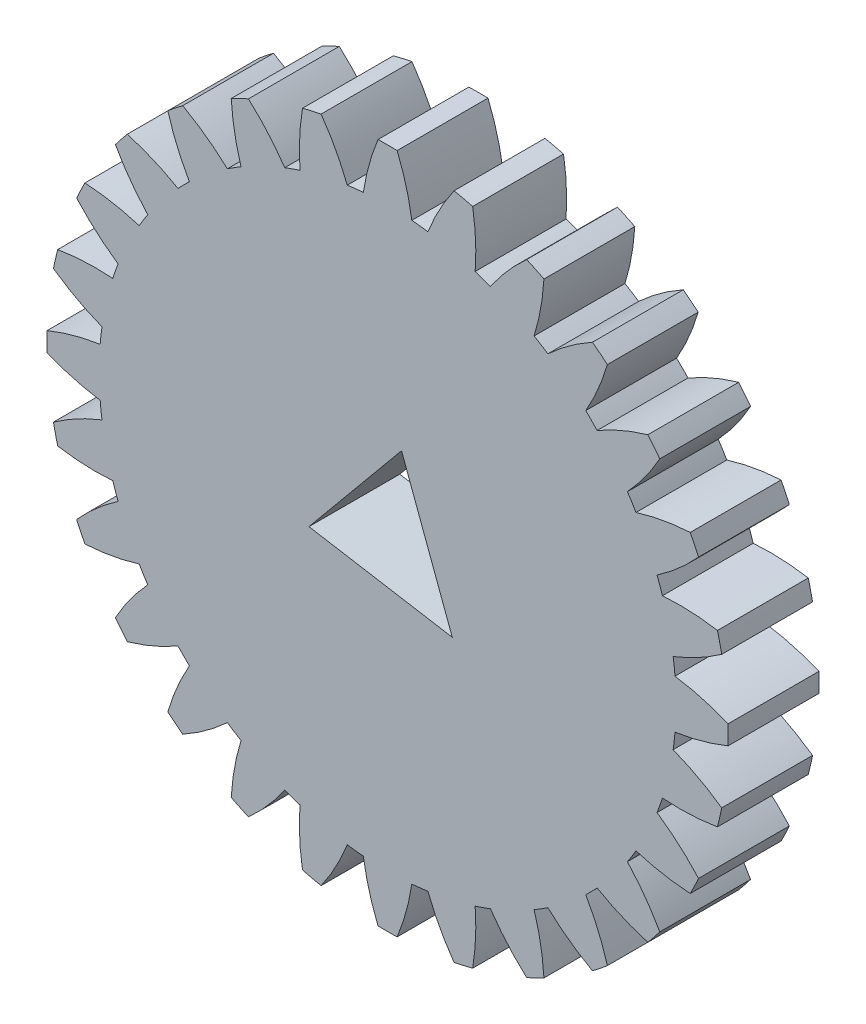
from build123d import *

# Parameters (mm, degrees)
BOSS_EXTRUDE1_DEPTH = 5


with BuildPart() as part:
    # Sketch1 → Boss-Extrude1 (new body)
    with BuildSketch(Plane.XY.offset(5)):
        with BuildLine():
            ThreePointArc((-4.820868329, 15.125305073), (-5.243180109, 14.984147869), (-5.661366831, 14.831201927))
            ThreePointArc((-5.661366831, 14.831201927), (-6.59033498, 16.033735197), (-7.658329818, 17.11468622))
            ThreePointArc((-7.658329818, 17.11468622), (-8.135320108, 16.893166273), (-8.605909959, 16.658355675))
            ThreePointArc((-8.605909959, 16.658355675), (-8.426672308, 15.149401748), (-8.065696106, 13.673337973))
            ThreePointArc((-8.065696106, 13.673337973), (-8.446009215, 13.441746663), (-8.819677449, 13.199580095))
            ThreePointArc((-8.819677449, 13.199580095), (-9.992943253, 14.165248486), (-11.274695462, 14.9814466))
            ThreePointArc((-11.274695462, 14.9814466), (-11.690433785, 14.659340296), (-12.096974691, 14.325700797))
            ThreePointArc((-12.096974691, 14.325700797), (-11.586457066, 12.894463625), (-10.906076201, 11.535732612))
            ThreePointArc((-10.906076201, 11.535732612), (-11.225320151, 11.225320151), (-11.535732612, 10.906076201))
            ThreePointArc((-11.535732612, 10.906076201), (-12.894463625, 11.586457066), (-14.325700797, 12.096974691))
            ThreePointArc((-14.325700797, 12.096974691), (-14.659340296, 11.690433785), (-14.9814466, 11.274695462))
            ThreePointArc((-14.9814466, 11.274695462), (-14.165248486, 9.992943253), (-13.199580095, 8.819677449))
            ThreePointArc((-13.199580095, 8.819677449), (-13.441746663, 8.446009215), (-13.673337973, 8.065696106))
            ThreePointArc((-13.673337973, 8.065696106), (-15.149401748, 8.426672308), (-16.658355675, 8.605909959))
            ThreePointArc((-16.658355675, 8.605909959), (-16.893166273, 8.135320108), (-17.11468622, 7.658329818))
            ThreePointArc((-17.11468622, 7.658329818), (-16.033735197, 6.59033498), (-14.831201927, 5.661366831))
            ThreePointArc((-14.831201927, 5.661366831), (-14.984147869, 5.243180109), (-15.125305073, 4.820868329))
            ThreePointArc((-15.125305073, 4.820868329), (-16.644685609, 4.844339014), (-18.15569104, 4.683308966))
            ThreePointArc((-18.15569104, 4.683308966), (-18.279898353, 4.172267512), (-18.389724008, 3.657943538))
            ThreePointArc((-18.389724008, 3.657943538), (-17.098223475, 2.857259791), (-15.719125365, 2.21917164))
            ThreePointArc((-15.719125365, 2.21917164), (-15.775181332, 1.777436058), (-15.818826219, 1.334302083))
            ThreePointArc((-15.818826219, 1.334302083), (-17.305335432, 1.019090334), (-18.742624245, 0.525867305))
            ThreePointArc((-18.742624245, 0.525867305), (-18.75, 0), (-18.742624245, -0.525867305))
            ThreePointArc((-18.742624245, -0.525867305), (-17.305335432, -1.019090334), (-15.818826219, -1.334302083))
            ThreePointArc((-15.818826219, -1.334302083), (-15.775181332, -1.777436058), (-15.719125365, -2.21917164))
            ThreePointArc((-15.719125365, -2.21917164), (-17.098223475, -2.857259791), (-18.389724008, -3.657943538))
            ThreePointArc((-18.389724008, -3.657943538), (-18.279898353, -4.172267512), (-18.15569104, -4.683308966))
            ThreePointArc((-18.15569104, -4.683308966), (-16.644685609, -4.844339014), (-15.125305073, -4.820868329))
            ThreePointArc((-15.125305073, -4.820868329), (-14.984147869, -5.243180109), (-14.831201927, -5.661366831))
            ThreePointArc((-14.831201927, -5.661366831), (-16.033735197, -6.59033498), (-17.11468622, -7.658329818))
            ThreePointArc((-17.11468622, -7.658329818), (-16.893166273, -8.135320108), (-16.658355675, -8.605909959))
            ThreePointArc((-16.658355675, -8.605909959), (-15.149401748, -8.426672308), (-13.673337973, -8.065696106))
            ThreePointArc((-13.673337973, -8.065696106), (-13.441746663, -8.446009215), (-13.199580095, -8.819677449))
            ThreePointArc((-13.199580095, -8.819677449), (-14.165248486, -9.992943253), (-14.9814466, -11.274695462))
            ThreePointArc((-14.9814466, -11.274695462), (-14.659340296, -11.690433785), (-14.325700797, -12.096974691))
            ThreePointArc((-14.325700797, -12.096974691), (-12.894463625, -11.586457066), (-11.535732612, -10.906076201))
            ThreePointArc((-11.535732612, -10.906076201), (-11.225320151, -11.225320151), (-10.906076201, -11.535732612))
            ThreePointArc((-10.906076201, -11.535732612), (-11.586457066, -12.894463625), (-12.096974691, -14.325700797))
            ThreePointArc((-12.096974691, -14.325700797), (-11.690433785, -14.659340296), (-11.274695462, -14.9814466))
            ThreePointArc((-11.274695462, -14.9814466), (-9.992943253, -14.165248486), (-8.819677449, -13.199580095))
            ThreePointArc((-8.819677449, -13.199580095), (-8.446009215, -13.441746663), (-8.065696106, -13.673337973))
            ThreePointArc((-8.065696106, -13.673337973), (-8.426672308, -15.149401748), (-8.605909959, -16.658355675))
            ThreePointArc((-8.605909959, -16.658355675), (-8.135320108, -16.893166273), (-7.658329818, -17.11468622))
            ThreePointArc((-7.658329818, -17.11468622), (-6.59033498, -16.033735197), (-5.661366831, -14.831201927))
            ThreePointArc((-5.661366831, -14.831201927), (-5.243180109, -14.984147869), (-4.820868329, -15.125305073))
            ThreePointArc((-4.820868329, -15.125305073), (-4.844339014, -16.644685609), (-4.683308966, -18.15569104))
            ThreePointArc((-4.683308966, -18.15569104), (-4.172267512, -18.279898353), (-3.657943538, -18.389724008))
            ThreePointArc((-3.657943538, -18.389724008), (-2.857259791, -17.098223475), (-2.21917164, -15.719125365))
            ThreePointArc((-2.21917164, -15.719125365), (-1.777436058, -15.775181332), (-1.334302083, -15.818826219))
            ThreePointArc((-1.334302083, -15.818826219), (-1.019090334, -17.305335432), (-0.525867305, -18.742624245))
            ThreePointArc((-0.525867305, -18.742624245), (0, -18.75), (0.525867305, -18.742624245))
            ThreePointArc((0.525867305, -18.742624245), (1.019090334, -17.305335432), (1.334302083, -15.818826219))
            ThreePointArc((1.334302083, -15.818826219), (1.777436058, -15.775181332), (2.21917164, -15.719125365))
            ThreePointArc((2.21917164, -15.719125365), (2.857259791, -17.098223475), (3.657943538, -18.389724008))
            ThreePointArc((3.657943538, -18.389724008), (4.172267512, -18.279898353), (4.683308966, -18.15569104))
            ThreePointArc((4.683308966, -18.15569104), (4.844339014, -16.644685609), (4.820868329, -15.125305073))
            ThreePointArc((4.820868329, -15.125305073), (5.243180109, -14.984147869), (5.661366831, -14.831201927))
            ThreePointArc((5.661366831, -14.831201927), (6.59033498, -16.033735197), (7.658329818, -17.11468622))
            ThreePointArc((7.658329818, -17.11468622), (8.135320108, -16.893166273), (8.605909959, -16.658355675))
            ThreePointArc((8.605909959, -16.658355675), (8.426672308, -15.149401748), (8.065696106, -13.673337973))
            ThreePointArc((8.065696106, -13.673337973), (8.446009215, -13.441746663), (8.819677449, -13.199580095))
            ThreePointArc((8.819677449, -13.199580095), (9.992943253, -14.165248486), (11.274695462, -14.9814466))
            ThreePointArc((11.274695462, -14.9814466), (11.690433785, -14.659340296), (12.096974691, -14.325700797))
            ThreePointArc((12.096974691, -14.325700797), (11.586457066, -12.894463625), (10.906076201, -11.535732612))
            ThreePointArc((10.906076201, -11.535732612), (11.225320151, -11.225320151), (11.535732612, -10.906076201))
            ThreePointArc((11.535732612, -10.906076201), (12.894463625, -11.586457066), (14.325700797, -12.096974691))
            ThreePointArc((14.325700797, -12.096974691), (14.659340296, -11.690433785), (14.9814466, -11.274695462))
            ThreePointArc((14.9814466, -11.274695462), (14.165248486, -9.992943253), (13.199580095, -8.819677449))
            ThreePointArc((13.199580095, -8.819677449), (13.441746663, -8.446009215), (13.673337973, -8.065696106))
            ThreePointArc((13.673337973, -8.065696106), (15.149401748, -8.426672308), (16.658355675, -8.605909959))
            ThreePointArc((16.658355675, -8.605909959), (16.893166273, -8.135320108), (17.11468622, -7.658329818))
            ThreePointArc((17.11468622, -7.658329818), (16.033735197, -6.59033498), (14.831201927, -5.661366831))
            ThreePointArc((14.831201927, -5.661366831), (14.984147869, -5.243180109), (15.125305073, -4.820868329))
            ThreePointArc((15.125305073, -4.820868329), (16.644685609, -4.844339014), (18.15569104, -4.683308966))
            ThreePointArc((18.15569104, -4.683308966), (18.279898353, -4.172267512), (18.389724008, -3.657943538))
            ThreePointArc((18.389724008, -3.657943538), (17.098223475, -2.857259791), (15.719125365, -2.21917164))
            ThreePointArc((15.719125365, -2.21917164), (15.775181332, -1.777436058), (15.818826219, -1.334302083))
            ThreePointArc((15.818826219, -1.334302083), (17.305335432, -1.019090334), (18.742624245, -0.525867305))
            ThreePointArc((18.742624245, -0.525867305), (18.75, 0), (18.742624245, 0.525867305))
            ThreePointArc((18.742624245, 0.525867305), (17.305335432, 1.019090334), (15.818826219, 1.334302083))
            ThreePointArc((15.818826219, 1.334302083), (15.775181332, 1.777436058), (15.719125365, 2.21917164))
            ThreePointArc((15.719125365, 2.21917164), (17.098223475, 2.857259791), (18.389724008, 3.657943538))
            ThreePointArc((18.389724008, 3.657943538), (18.279898353, 4.172267512), (18.15569104, 4.683308966))
            ThreePointArc((18.15569104, 4.683308966), (16.644685609, 4.844339014), (15.125305073, 4.820868329))
            ThreePointArc((15.125305073, 4.820868329), (14.984147869, 5.243180109), (14.831201927, 5.661366831))
            ThreePointArc((14.831201927, 5.661366831), (16.033735197, 6.59033498), (17.11468622, 7.658329818))
            ThreePointArc((17.11468622, 7.658329818), (16.893166273, 8.135320108), (16.658355675, 8.605909959))
            ThreePointArc((16.658355675, 8.605909959), (15.149401748, 8.426672308), (13.673337973, 8.065696106))
            ThreePointArc((13.673337973, 8.065696106), (13.441746663, 8.446009215), (13.199580095, 8.819677449))
            ThreePointArc((13.199580095, 8.819677449), (14.165248486, 9.992943253), (14.9814466, 11.274695462))
            ThreePointArc((14.9814466, 11.274695462), (14.659340296, 11.690433785), (14.325700797, 12.096974691))
            ThreePointArc((14.325700797, 12.096974691), (12.894463625, 11.586457066), (11.535732612, 10.906076201))
            ThreePointArc((11.535732612, 10.906076201), (11.225320151, 11.225320151), (10.906076201, 11.535732612))
            ThreePointArc((10.906076201, 11.535732612), (11.586457066, 12.894463625), (12.096974691, 14.325700797))
            ThreePointArc((12.096974691, 14.325700797), (11.690433785, 14.659340296), (11.274695462, 14.9814466))
            ThreePointArc((11.274695462, 14.9814466), (9.992943253, 14.165248486), (8.819677449, 13.199580095))
            ThreePointArc((8.819677449, 13.199580095), (8.446009215, 13.441746663), (8.065696106, 13.673337973))
            ThreePointArc((8.065696106, 13.673337973), (8.426672308, 15.149401748), (8.605909959, 16.658355675))
            ThreePointArc((8.605909959, 16.658355675), (8.135320108, 16.893166273), (7.658329818, 17.11468622))
            ThreePointArc((7.658329818, 17.11468622), (6.59033498, 16.033735197), (5.661366831, 14.831201927))
            ThreePointArc((5.661366831, 14.831201927), (5.243180109, 14.984147869), (4.820868329, 15.125305073))
            ThreePointArc((4.820868329, 15.125305073), (4.844339014, 16.644685609), (4.683308966, 18.15569104))
            ThreePointArc((4.683308966, 18.15569104), (4.172267512, 18.279898353), (3.657943538, 18.389724008))
            ThreePointArc((3.657943538, 18.389724008), (2.857259791, 17.098223475), (2.21917164, 15.719125365))
            ThreePointArc((2.21917164, 15.719125365), (1.777436058, 15.775181332), (1.334302083, 15.818826219))
            ThreePointArc((1.334302083, 15.818826219), (1.019090334, 17.305335432), (0.525867305, 18.742624245))
            ThreePointArc((0.525867305, 18.742624245), (0, 18.75), (-0.525867305, 18.742624245))
            ThreePointArc((-0.525867305, 18.742624245), (-1.019090334, 17.305335432), (-1.334302083, 15.818826219))
            ThreePointArc((-1.334302083, 15.818826219), (-1.777436058, 15.775181332), (-2.21917164, 15.719125365))
            ThreePointArc((-2.21917164, 15.719125365), (-2.857259791, 17.098223475), (-3.657943538, 18.389724008))
            ThreePointArc((-3.657943538, 18.389724008), (-4.172267512, 18.279898353), (-4.683308966, 18.15569104))
            ThreePointArc((-4.683308966, 18.15569104), (-4.844339014, 16.644685609), (-4.820868329, 15.125305073))
        make_face()
        Polygon((0.768000768, 4.554504161), (3.560315921, -2.942360256), (-4.328316689, -1.612143905), align=None, mode=Mode.SUBTRACT)
    extrude(amount=-BOSS_EXTRUDE1_DEPTH)


solid = part.part
